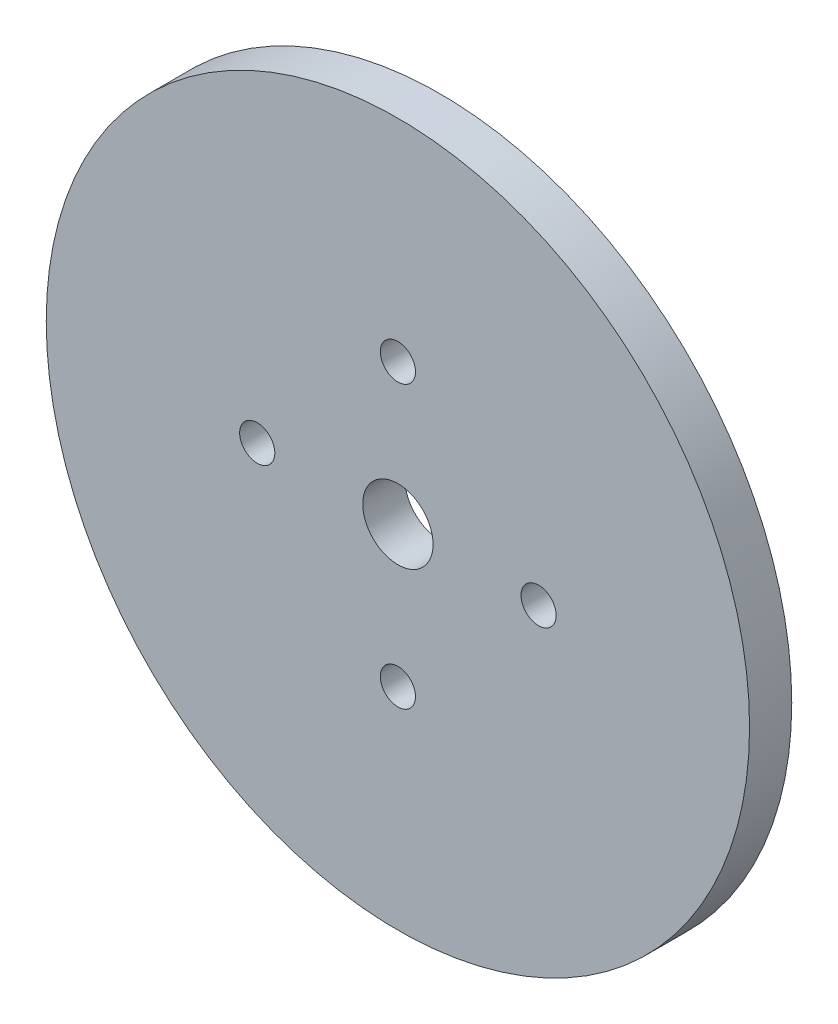
from build123d import *

# Parameters (mm, degrees)
SKETCH1_R           = 50
SKETCH1_R_2         = 5
BOSS_EXTRUDE1_DEPTH = 6
SKETCH2_R           = 2.5
CUT_EXTRUDE1_DEPTH  = 7


with BuildPart() as part:
    # Sketch1 → Boss-Extrude1 (new body)
    with BuildSketch(Plane.XY):
        Circle(SKETCH1_R)
        Circle(SKETCH1_R_2, mode=Mode.SUBTRACT)
    extrude(amount=BOSS_EXTRUDE1_DEPTH)

    # Sketch2 → Cut-Extrude1 (cut, through all)
    with BuildSketch(Plane(origin=(0, 0, 0), x_dir=(-1, 0, 0), z_dir=(0, 0, -1))):
        with Locations((0, 20)):
            Circle(SKETCH2_R)
        with Locations((20, 0)):
            Circle(SKETCH2_R)
        with Locations((0, -20)):
            Circle(SKETCH2_R)
        with Locations((-20, 0)):
            Circle(SKETCH2_R)
    extrude(amount=-CUT_EXTRUDE1_DEPTH, mode=Mode.SUBTRACT)


solid = part.part
